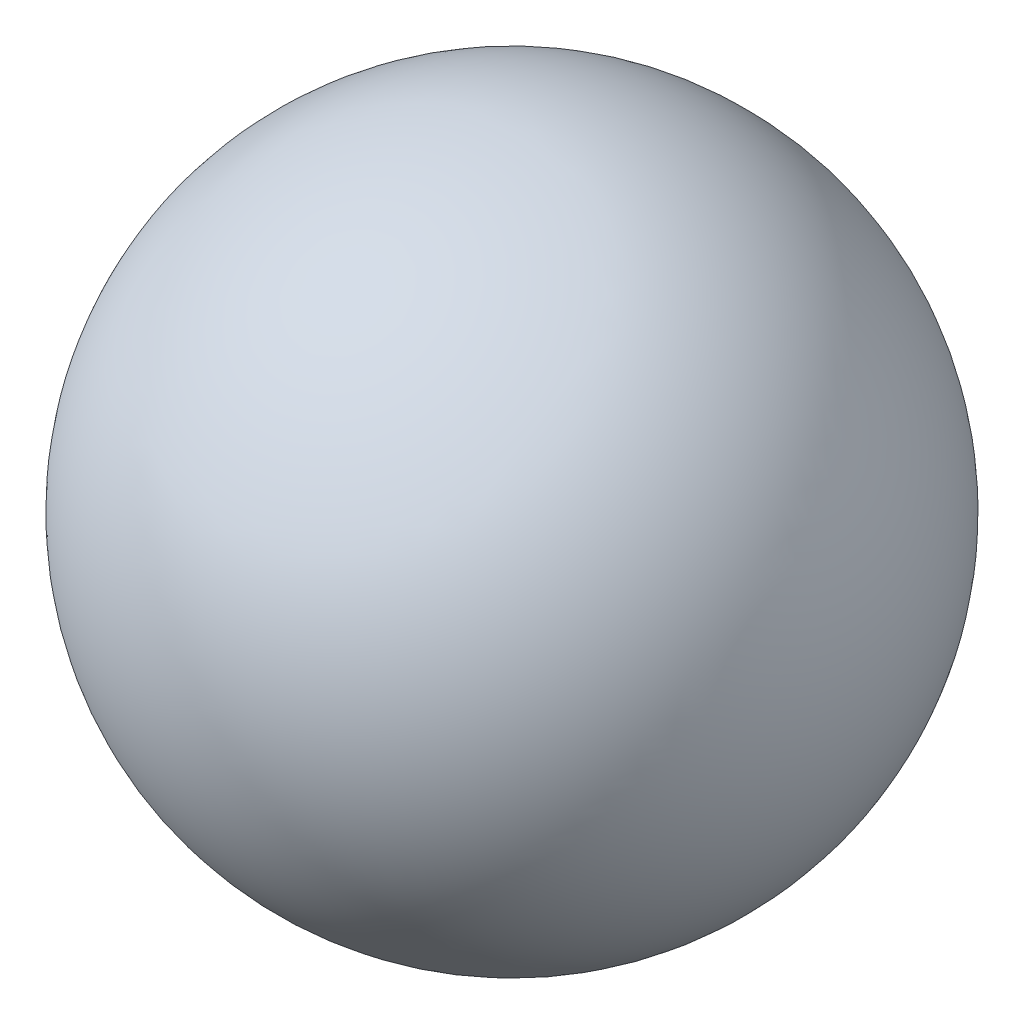
from build123d import *


with BuildPart() as part:
    # Esquisse1 → Base-Révolution (revolve)
    with BuildSketch(Plane.XY):
        with BuildLine():
            Line((1, 4.25), (4, 4.25))
            ThreePointArc((4, 4.25), (2.5, 5.75), (1, 4.25))
        make_face()
    revolve(axis=Axis((2.5, 4.25, 0), (1, 0, 0)))


solid = part.part
